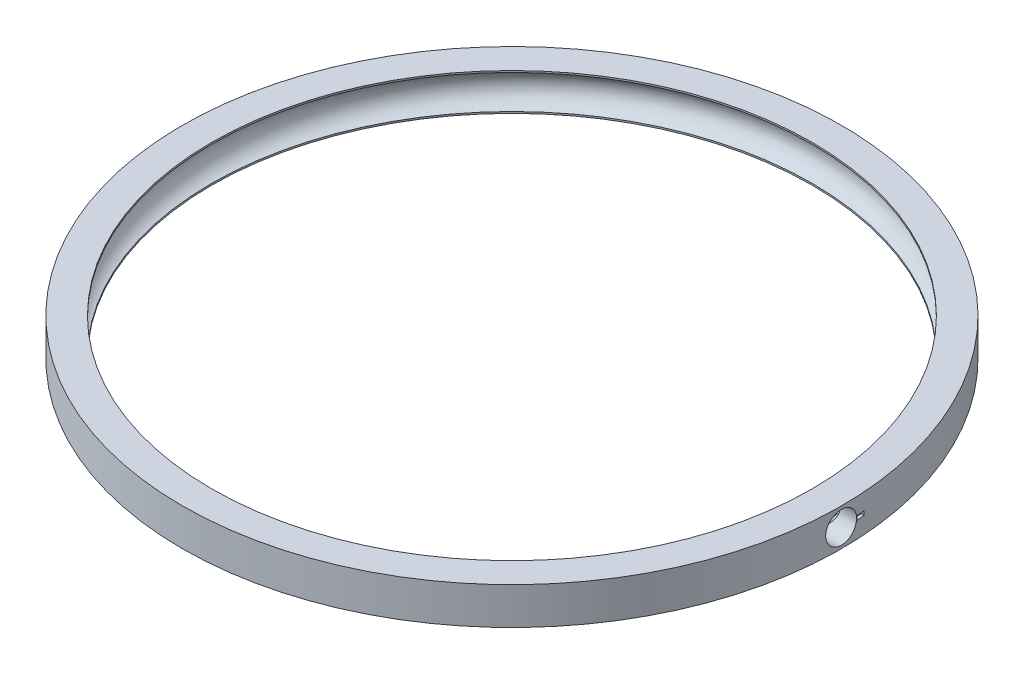
from build123d import *

# Parameters (mm, degrees)
SKETCH1_R                 = 53.25
SKETCH1_R_2               = 48.5
BOSS_EXTRUDE1_DEPTH       = 6
SKETCH3_R                 = 2.85
SKETCH4_R                 = 2.5
CUT_EXTRUDE1_DEPTH        = 120
CUT_EXTRUDE2_REACH        = 78.046
CUT_EXTRUDE2_START_RADIUS = 53.25
CUT_EXTRUDE2_END_RADIUS   = 53.25
SKETCH6_W                 = 1.240344628
SKETCH6_H                 = 0.651674146


with BuildPart() as part:
    # Sketch1 → Boss-Extrude1 (new body)
    with BuildSketch(Plane(origin=(0, 0, 0), x_dir=(1, 0, 0), z_dir=(0, 1, 0))):
        with Locations(Location((0, 0, 0), (0, 0, 270))):
            Circle(SKETCH1_R)
        with Locations(Location((0, 0, 0), (0, 0, 270))):
            Circle(SKETCH1_R_2, mode=Mode.SUBTRACT)
    extrude(amount=BOSS_EXTRUDE1_DEPTH)

    # Sketch3 → Cut-Revolve1 (revolve, cut)
    with BuildSketch(Plane.XY, mode=Mode.PRIVATE) as cut_revolve1_sk:
        with Locations((-47.7, 3)):
            Circle(SKETCH3_R)
    revolve(cut_revolve1_sk.sketch.rotate(Axis((0, 0, 0), (0, 1, 0)), 270), axis=Axis((0, 0, 0), (0, 1, 0)), mode=Mode.SUBTRACT)

    # Sketch4 → Cut-Extrude1 (cut)
    with BuildSketch(Plane(origin=(0, 0, 0), x_dir=(0, 0, -1), z_dir=(1, 0, 0))):
        with Locations(Location((0, 3, 0), (0, 0, 180))):
            Circle(SKETCH4_R)
    extrude(amount=CUT_EXTRUDE1_DEPTH, mode=Mode.SUBTRACT)

    # Cut-Extrude2: from a cylinder face, 78.046 long prism both ways, kept between that surface and its translate by the depth
    cut_extrude2_start = Plane(origin=(0, 3, 0), z_dir=(0, -1, 0)) * Cylinder(CUT_EXTRUDE2_START_RADIUS, 263.592, mode=Mode.PRIVATE)
    cut_extrude2_end = Plane(origin=(-0.5, 3, 0), z_dir=(0, -1, 0)) * Cylinder(CUT_EXTRUDE2_END_RADIUS, 263.592, mode=Mode.PRIVATE)
    # Sketch6 → Cut-Extrude2 (cut, from a surface)
    with BuildSketch(Plane(origin=(0, 0, 0), x_dir=(0, 0, -1), z_dir=(1, 0, 0)), mode=Mode.PRIVATE) as cut_extrude2_sk1:
        with Locations((3.176747556, 3)):
            Rectangle(SKETCH6_W, SKETCH6_H)
    cut_extrude2_tool1 = extrude(cut_extrude2_sk1.sketch, amount=CUT_EXTRUDE2_REACH, both=True, mode=Mode.PRIVATE)
    add(((cut_extrude2_tool1 & cut_extrude2_start) - cut_extrude2_end).solids().sort_by_distance((52.901527, 3, -3.176748))[0], mode=Mode.SUBTRACT)


solid = part.part
